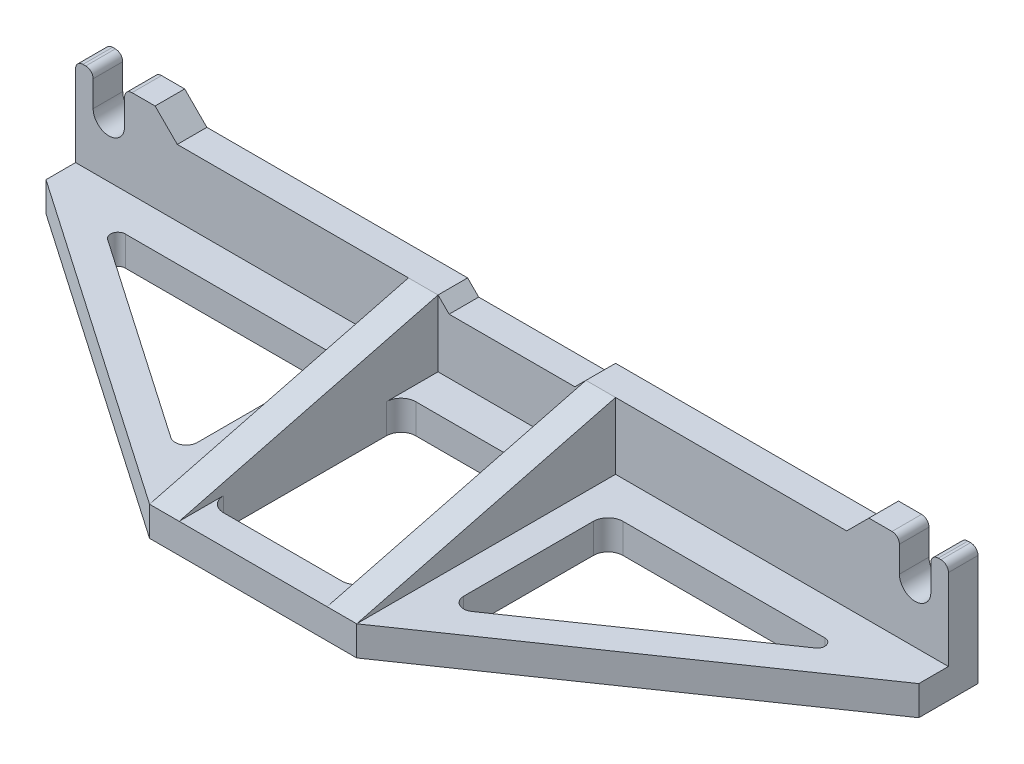
from build123d import *

# Parameters (mm, degrees)
BOSS_EXTRUDE1_DEPTH = 8
BOSS_EXTRUDE2_DEPTH = 8
BOSS_EXTRUDE3_DEPTH = 8
BOSS_EXTRUDE4_DEPTH = 8
SKETCH6_W           = 40
SKETCH6_H           = 52
CUT_EXTRUDE1_DEPTH  = 9
CUT_EXTRUDE2_DEPTH  = 9
FILLET1_R           = 4
FILLET2_R           = 2
FILLET3_R           = 4
FILLET4_R           = 3
FILLET5_R           = 2


with BuildPart() as part:
    # Sketch1 → Boss-Extrude1 (new body)
    with BuildSketch(Plane.XY):
        with BuildLine():
            Line((4.25, 9), (4.25, 0))
            ThreePointArc((4.25, 0), (0, -4.25), (-4.25, 0))
            Line((-4.25, 0), (-4.25, 9))
            Line((-4.25, 9), (-12.5, 9))
            Line((-12.5, 9), (-18.5, 3))
            Line((-18.5, 3), (-89, 3))
            Line((-89, 3), (-92, 0))
            Line((-92, 0), (-126, 0))
            Line((-126, 0), (-129, 3))
            Line((-129, 3), (-199.5, 3))
            Line((-199.5, 3), (-205.5, 9))
            Line((-205.5, 9), (-213.75, 9))
            Line((-213.75, 9), (-213.75, 0))
            ThreePointArc((-213.75, 0), (-218, -4.25), (-222.25, 0))
            Line((-222.25, 0), (-222.25, 9))
            Line((-222.25, 9), (-227, 9))
            Line((-227, 9), (-227, -23))
            Line((-227, -23), (9, -23))
            Line((9, -23), (9, 9))
            Line((9, 9), (4.25, 9))
        make_face()
    extrude(amount=BOSS_EXTRUDE1_DEPTH)

    # Sketch2 → Boss-Extrude2 (add)
    with BuildSketch(Plane.XZ.offset(23)):
        Polygon((-227, 8), (-227, 16), (-137, 78), (-81, 78), (9, 16), (9, 8), align=None)
    extrude(amount=-BOSS_EXTRUDE2_DEPTH)

    # Sketch4 → Boss-Extrude3 (add)
    with BuildSketch(Plane(origin=(-81, 0, 0), x_dir=(0, 0, -1), z_dir=(1, 0, 0))):
        Polygon((-78, -15), (-8, 3), (-8, 0), (-8, -15), align=None)
    extrude(amount=-BOSS_EXTRUDE3_DEPTH)

    # Sketch5 → Boss-Extrude4 (add)
    with BuildSketch(Plane(origin=(-137, 0, 0), x_dir=(0, 0, -1), z_dir=(1, 0, 0))):
        Polygon((-8, 3), (-78, -15), (-8, -15), (-8, 0), align=None)
    extrude(amount=BOSS_EXTRUDE4_DEPTH)

    # Sketch6 → Cut-Extrude1 (cut, through all)
    with BuildSketch(Plane(origin=(0, -15, 0), x_dir=(1, 0, 0), z_dir=(0, 1, 0))):
        with Locations((-109, -44)):
            Rectangle(SKETCH6_W, SKETCH6_H)
    extrude(amount=-CUT_EXTRUDE1_DEPTH, mode=Mode.SUBTRACT)

    # Sketch7 → Cut-Extrude2 (cut, through all)
    with BuildSketch(Plane(origin=(0, -15, 0), x_dir=(1, 0, 0), z_dir=(0, 1, 0))):
        Polygon((-73, -18), (-8.004981773, -18), (-73, -62.77434589), align=None)
        Polygon((-145, -18), (-209.995018227, -18), (-145, -62.77434589), align=None)
    extrude(amount=-CUT_EXTRUDE2_DEPTH, mode=Mode.SUBTRACT)

    # Fillet1
    fillet1_edges = [part.edges().sort_by_distance(p)[0] for p in [
        (-129, -19, 18),
        (-89, -19, 18),
        (-73, -19, 18),
        (-145, -19, 18),
    ]]
    fillet(fillet1_edges, radius=FILLET1_R)

    # Fillet2
    fillet2_edges = [part.edges().sort_by_distance(p)[0] for p in [
        (-8.004981773, -19, 18),
        (-209.995018227, -19, 18),
    ]]
    fillet(fillet2_edges, radius=FILLET2_R)

    # Fillet3
    fillet3_edges = [part.edges().sort_by_distance(p)[0] for p in [
        (-129, -19, 70),
        (-89, -19, 70),
    ]]
    fillet(fillet3_edges, radius=FILLET3_R)

    # Fillet4
    fillet4_edges = [part.edges().sort_by_distance(p)[0] for p in [
        (-73, -19, 62.77434589),
        (-145, -19, 62.77434589),
    ]]
    fillet(fillet4_edges, radius=FILLET4_R)

    # Fillet5
    fillet5_edges = [part.edges().sort_by_distance(p)[0] for p in [
        (9, 9, 4),
        (4.25, 9, 4),
        (-4.25, 9, 4),
        (-213.75, 9, 4),
        (-222.25, 9, 4),
        (-227, 9, 4),
    ]]
    fillet(fillet5_edges, radius=FILLET5_R)


solid = part.part
